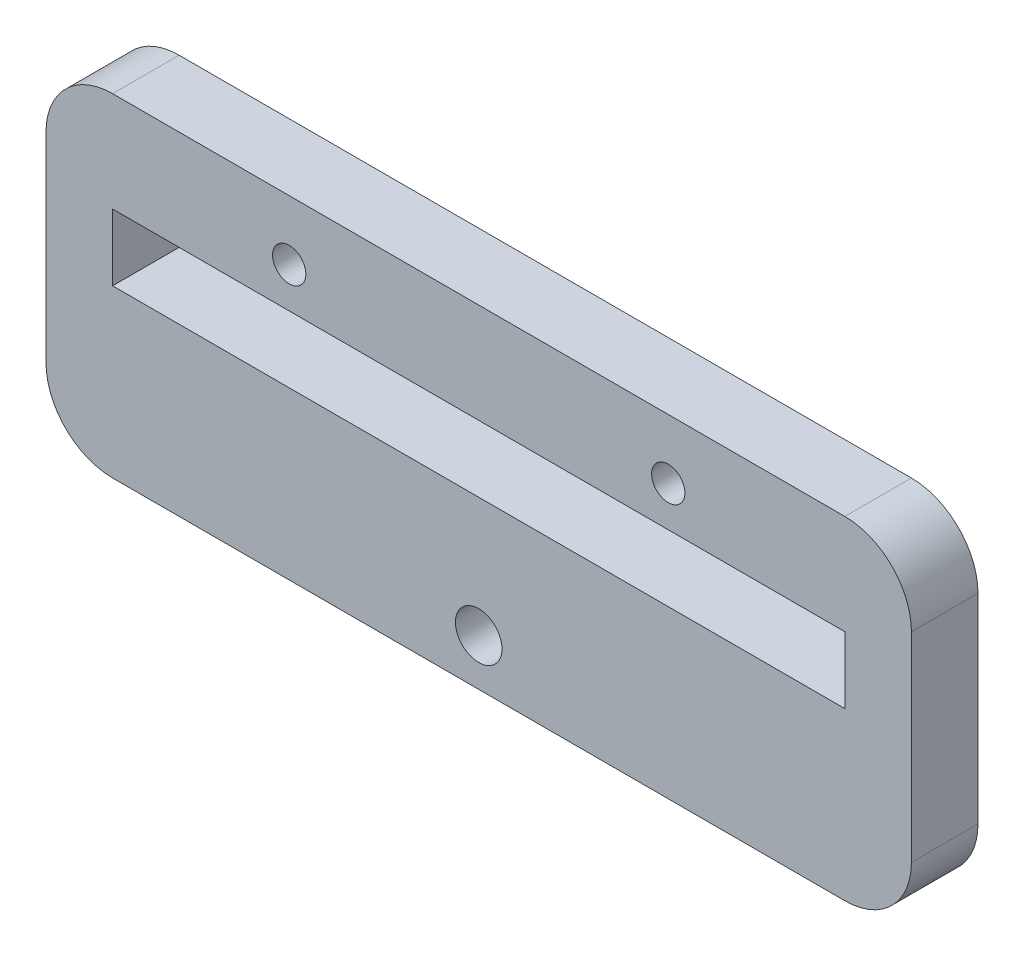
from build123d import *

# Parameters (mm, degrees)
SKETCH1_W           = 130
SKETCH1_H           = 50
SKETCH1_R           = 2.5
SKETCH1_R_2         = 3.5
SKETCH1_W_2         = 110
SKETCH1_H_2         = 10
BOSS_EXTRUDE2_DEPTH = 10
FILLET1_R           = 10


with BuildPart() as part:
    # Sketch1 → Boss-Extrude2 (new body)
    with BuildSketch(Plane.XY):
        with Locations((65, 25)):
            Rectangle(SKETCH1_W, SKETCH1_H)
        with Locations((36.53, 41.03)):
            Circle(SKETCH1_R, mode=Mode.SUBTRACT)
        with Locations((93.47, 41.03)):
            Circle(SKETCH1_R, mode=Mode.SUBTRACT)
        with Locations((65, 7)):
            Circle(SKETCH1_R_2, mode=Mode.SUBTRACT)
        with Locations((65, 30)):
            Rectangle(SKETCH1_W_2, SKETCH1_H_2, mode=Mode.SUBTRACT)
    extrude(amount=BOSS_EXTRUDE2_DEPTH)

    # Fillet1
    fillet1_edges = [part.edges().sort_by_distance(p)[0] for p in [
        (0, 50, 5),
        (130, 50, 5),
        (130, 0, 5),
        (0, 0, 5),
    ]]
    fillet(fillet1_edges, radius=FILLET1_R)


solid = part.part
